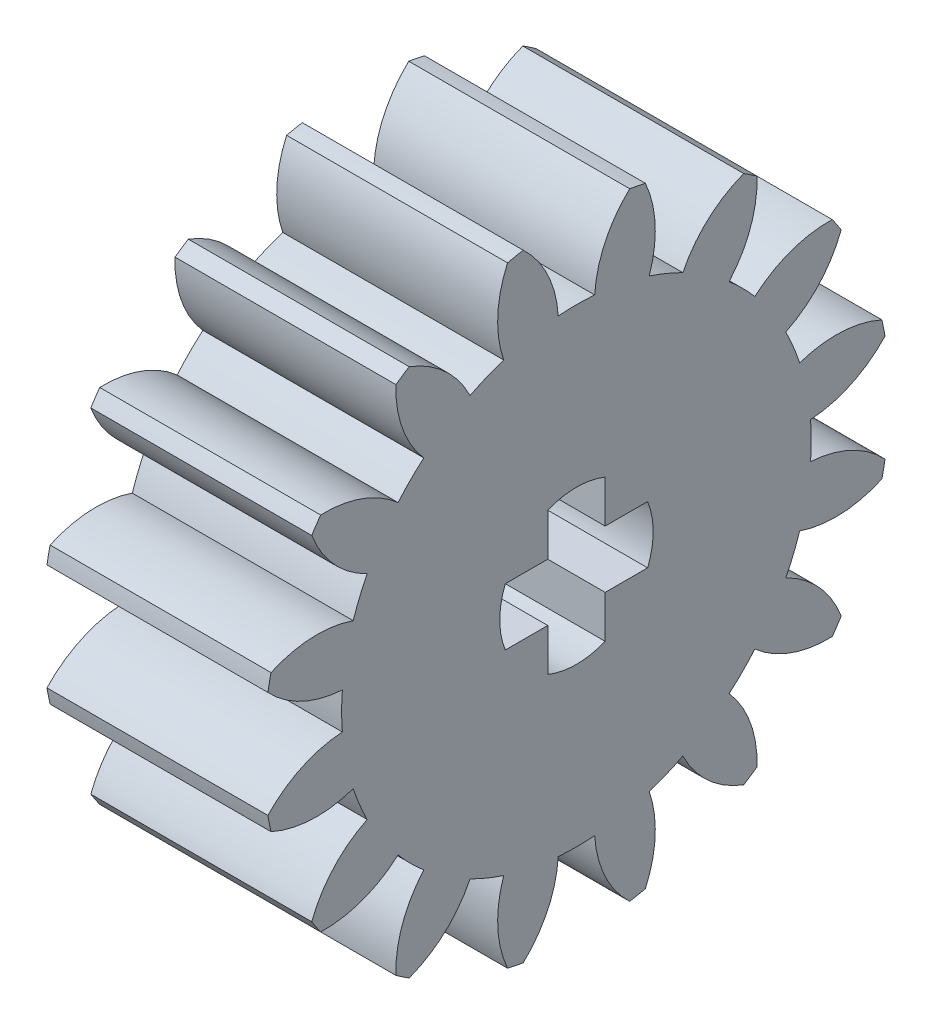
from build123d import *

# Parameters (mm, degrees)
BASPROSKE_W        = 6.35
BASPROSKE_H        = 9
TOOTHCUT_DEPTH     = 15.224011389
TEETHCUTS_COUNT    = 16
TEETHCUTS_ANGLE    = 337.5
BORSKE_R           = 0.5
BORE_DEPTH         = 50.0008636
CUT_EXTRUDE1_DEPTH = 10


with BuildPart() as part:
    # BasProSke → Base-Revolve (revolve)
    with BuildSketch(Plane(origin=(0, 0, 0), x_dir=(1, 0, 0), z_dir=(0, 1, 0)), mode=Mode.PRIVATE) as base_revolve_sk:
        with Locations((3.175, 4.5)):
            Rectangle(BASPROSKE_W, BASPROSKE_H)
    revolve(base_revolve_sk.sketch.rotate(Axis((-10, 0, 0), (1, 0, 0)), 180), axis=Axis((-10, 0, 0), (1, 0, 0)))

    # TooCutSke → ToothCut (cut, through all)
    with BuildSketch(Plane(origin=(0, 0, 0), x_dir=(0, 0, -1), z_dir=(1, 0, 0))):
        with BuildLine():
            ThreePointArc((0.523792937, 6.728643397), (0, 6.749), (-0.523792937, 6.728643397))
            ThreePointArc((-0.523792937, 6.728643397), (-0.828704482, 7.90962059), (-1.553355277, 8.890721711))
            ThreePointArc((-1.553355277, 8.890721711), (0, 9.0254), (1.553355277, 8.890721711))
            ThreePointArc((1.553355277, 8.890721711), (0.828704482, 7.90962059), (0.523792937, 6.728643397))
        make_face()
    toothcut = extrude(amount=TOOTHCUT_DEPTH, mode=Mode.SUBTRACT)

    # TeethCuts: ToothCut ×16 about axis
    teethcuts_axis = Axis((-10, 0, 0), (1, 0, 0))
    for i in range(1, TEETHCUTS_COUNT):
        add(toothcut.rotate(teethcuts_axis, i * TEETHCUTS_ANGLE / (TEETHCUTS_COUNT - 1)), mode=Mode.SUBTRACT)

    # BorSke → Bore (cut, symmetric)
    with BuildSketch(Plane(origin=(0, 0, 0), x_dir=(0, 0, -1), z_dir=(1, 0, 0))):
        with Locations(Location((0, 0, 0), (0, 0, 180))):
            Circle(BORSKE_R)
    extrude(amount=BORE_DEPTH, both=True, mode=Mode.SUBTRACT)

    # Sketch1 → Cut-Extrude1 (cut)
    with BuildSketch(Plane(origin=(6.35, 0, 0), x_dir=(0, 0, -1), z_dir=(1, 0, 0))):
        with BuildLine():
            ThreePointArc((0.824890579, 2.044890679), (0, 2.2049994), (-0.824890579, 2.044890679))
            Line((-0.824890579, 2.044890679), (-0.824890579, 0.824890579))
            Line((-0.824890579, 0.824890579), (-2.044890679, 0.824890579))
            ThreePointArc((-2.044890679, 0.824890579), (-2.2049994, 0), (-2.044890679, -0.824890579))
            Line((-2.044890679, -0.824890579), (-0.824890579, -0.824890579))
            Line((-0.824890579, -0.824890579), (-0.824890579, -2.044890679))
            ThreePointArc((-0.824890579, -2.044890679), (0, -2.2049994), (0.824890579, -2.044890679))
            Line((0.824890579, -2.044890679), (0.824890579, -0.824890579))
            Line((0.824890579, -0.824890579), (2.044890679, -0.824890579))
            ThreePointArc((2.044890679, -0.824890579), (2.164602166, -0.420142615), (2.2049994, 0))
            ThreePointArc((2.2049994, 0), (2.164602166, 0.420142615), (2.044890679, 0.824890579))
            Line((2.044890679, 0.824890579), (0.824890579, 0.824890579))
            Line((0.824890579, 0.824890579), (0.824890579, 2.044890679))
        make_face()
    extrude(amount=-CUT_EXTRUDE1_DEPTH, mode=Mode.SUBTRACT)


solid = part.part
